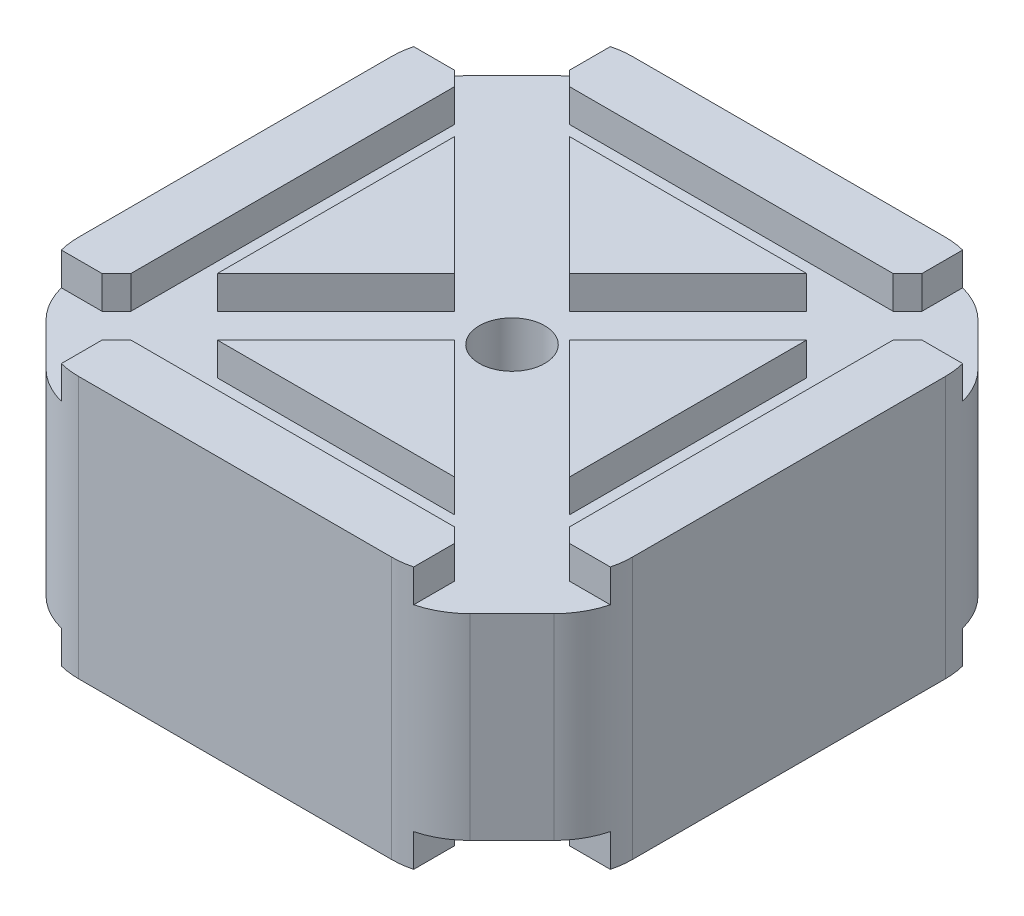
from build123d import *

# Parameters (mm, degrees)
BOSS_EXTRUDE1_DEPTH = 10
SKETCH18_W          = 3.3
SKETCH18_H          = 2.5
CUT_EXTRUDE10_DEPTH = 43.3
SKETCH19_W          = 3.3
SKETCH19_H          = 2.5
CUT_EXTRUDE11_DEPTH = 43.3
SKETCH20_W          = 6.221233688
SKETCH20_H          = 2.5
CUT_EXTRUDE12_DEPTH = 57.710616844
SKETCH21_W          = 6.221233688
SKETCH21_H          = 2.5
CUT_EXTRUDE13_DEPTH = 57.710616844
SKETCH22_R          = 2.5
CUT_EXTRUDE14_DEPTH = 8.5
CUT_EXTRUDE15_DEPTH = 18.5
FILLET8_R           = 6


with BuildPart() as part:
    # Sketch1 → Boss-Extrude1 (new body)
    with BuildSketch(Plane(origin=(0, 0, 0), x_dir=(1, 0, 0), z_dir=(0, 1, 0))):
        Polygon((-21.15, 16.750923472), (-16.750923472, 21.15), (16.750923472, 21.15), (21.15, 16.750923472), (21.15, -16.750923472), (16.750923472, -21.15), (-16.750923472, -21.15), (-21.15, -16.750923472), align=None)
    boss_extrude1 = extrude(amount=BOSS_EXTRUDE1_DEPTH)

    # Sketch18 → Cut-Extrude10 (cut, through all)
    with BuildSketch(Plane.XY.offset(21.15)):
        with Locations((15.100923472, 8.75)):
            Rectangle(SKETCH18_W, SKETCH18_H)
        with Locations((-15.100923472, 8.75)):
            Rectangle(SKETCH18_W, SKETCH18_H)
    cut_extrude10 = extrude(amount=-CUT_EXTRUDE10_DEPTH, mode=Mode.SUBTRACT)

    # Sketch19 → Cut-Extrude11 (cut, through all)
    with BuildSketch(Plane(origin=(21.15, 0, 0), x_dir=(0, 0, -1), z_dir=(1, 0, 0))):
        with Locations((-15.100923472, 8.75)):
            Rectangle(SKETCH19_W, SKETCH19_H)
        with Locations((15.100923472, 8.75)):
            Rectangle(SKETCH19_W, SKETCH19_H)
    cut_extrude11 = extrude(amount=-CUT_EXTRUDE11_DEPTH, mode=Mode.SUBTRACT)

    # Sketch20 → Cut-Extrude12 (cut, through all)
    with BuildSketch(Plane(origin=(18.950461736, 0, 18.950461736), x_dir=(0.707106781, 0, -0.707106781), z_dir=(0.707106781, 0, 0.707106781))):
        with Locations((0, 8.75)):
            Rectangle(SKETCH20_W, SKETCH20_H)
    cut_extrude12 = extrude(amount=-CUT_EXTRUDE12_DEPTH, mode=Mode.SUBTRACT)

    # Sketch21 → Cut-Extrude13 (cut, through all)
    with BuildSketch(Plane(origin=(-18.950461736, 0, 18.950461736), x_dir=(0.707106781, 0, 0.707106781), z_dir=(-0.707106781, 0, 0.707106781))):
        with Locations((0, 8.75)):
            Rectangle(SKETCH21_W, SKETCH21_H)
    cut_extrude13 = extrude(amount=-CUT_EXTRUDE13_DEPTH, mode=Mode.SUBTRACT)

    # Sketch22 → Cut-Extrude14 (cut, through all)
    with BuildSketch(Plane(origin=(0, 7.5, 0), x_dir=(1, 0, 0), z_dir=(0, 1, 0))):
        Circle(SKETCH22_R)
    cut_extrude14 = extrude(amount=-CUT_EXTRUDE14_DEPTH, mode=Mode.SUBTRACT)

    # Mirror1: Boss-Extrude1, Cut-Extrude10, Cut-Extrude11, Cut-Extrude12, Cut-Extrude13, Cut-Extrude14 across plane
    add(boss_extrude1.mirror(Plane(origin=(0, 0, 0), x_dir=(0, 0, 1), z_dir=(0, -1, 0))))
    add(cut_extrude10.mirror(Plane(origin=(0, 0, 0), x_dir=(0, 0, 1), z_dir=(0, -1, 0))), mode=Mode.SUBTRACT)
    add(cut_extrude11.mirror(Plane(origin=(0, 0, 0), x_dir=(0, 0, 1), z_dir=(0, -1, 0))), mode=Mode.SUBTRACT)
    add(cut_extrude12.mirror(Plane(origin=(0, 0, 0), x_dir=(0, 0, 1), z_dir=(0, -1, 0))), mode=Mode.SUBTRACT)
    add(cut_extrude13.mirror(Plane(origin=(0, 0, 0), x_dir=(0, 0, 1), z_dir=(0, -1, 0))), mode=Mode.SUBTRACT)
    add(cut_extrude14.mirror(Plane(origin=(0, 0, 0), x_dir=(0, 0, 1), z_dir=(0, -1, 0))), mode=Mode.SUBTRACT)

    # Sketch23 → Cut-Extrude15 (cut, through all)
    with BuildSketch(Plane(origin=(0, 7.5, 0), x_dir=(1, 0, 0), z_dir=(0, 1, 0))):
        Polygon((-21.15, -14.432485579), (-14.432485579, -21.15), (-16.750923472, -21.15), (-21.15, -16.750923472), align=None)
        Polygon((-21.15, 14.432485579), (-14.432485579, 21.15), (-16.750923472, 21.15), (-21.15, 16.750923472), align=None)
        Polygon((14.432485579, 21.15), (21.15, 14.432485579), (21.15, 16.750923472), (16.750923472, 21.15), align=None)
        Polygon((14.432485579, -21.15), (21.15, -14.432485579), (21.15, -16.750923472), (16.750923472, -21.15), align=None)
    extrude(amount=-CUT_EXTRUDE15_DEPTH, mode=Mode.SUBTRACT)

    # Fillet8
    fillet8_edges = [part.edges().sort_by_distance(p)[0] for p in [
        (14.432485579, 0, -21.15),
        (21.15, 0, -14.432485579),
        (-21.15, 0, -14.432485579),
        (-14.432485579, 0, -21.15),
        (-14.432485579, 0, 21.15),
        (-21.15, 0, 14.432485579),
        (21.15, 0, 14.432485579),
        (14.432485579, 0, 21.15),
    ]]
    fillet(fillet8_edges, radius=FILLET8_R)


solid = part.part
